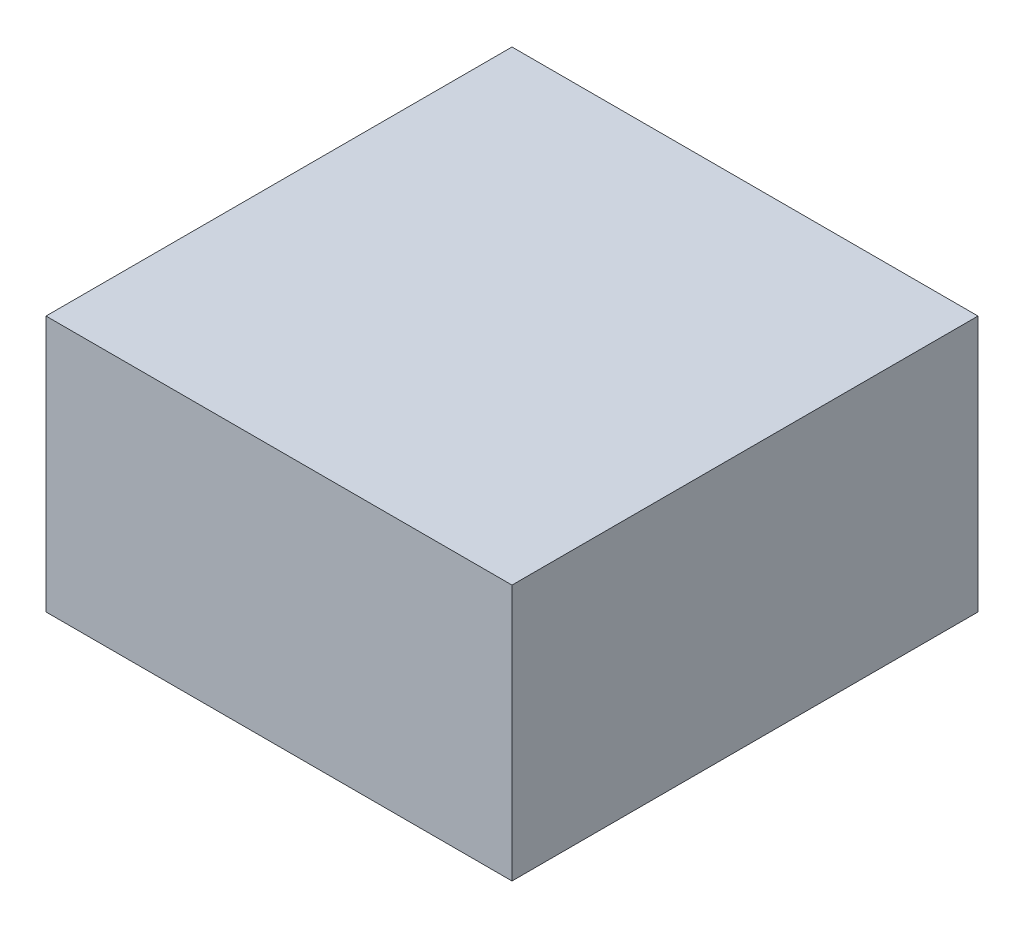
from build123d import *

# Parameters (mm, degrees)
CROQUIS1_W              = 1
CROQUIS1_H              = 1
SALIENTE_EXTRUIR1_DEPTH = 0.55


with BuildPart() as part:
    # Croquis1 → Saliente-Extruir1 (new body)
    with BuildSketch(Plane(origin=(0, 0, 0), x_dir=(1, 0, 0), z_dir=(0, 1, 0))):
        Rectangle(CROQUIS1_W, CROQUIS1_H)
    extrude(amount=SALIENTE_EXTRUIR1_DEPTH)


solid = part.part
